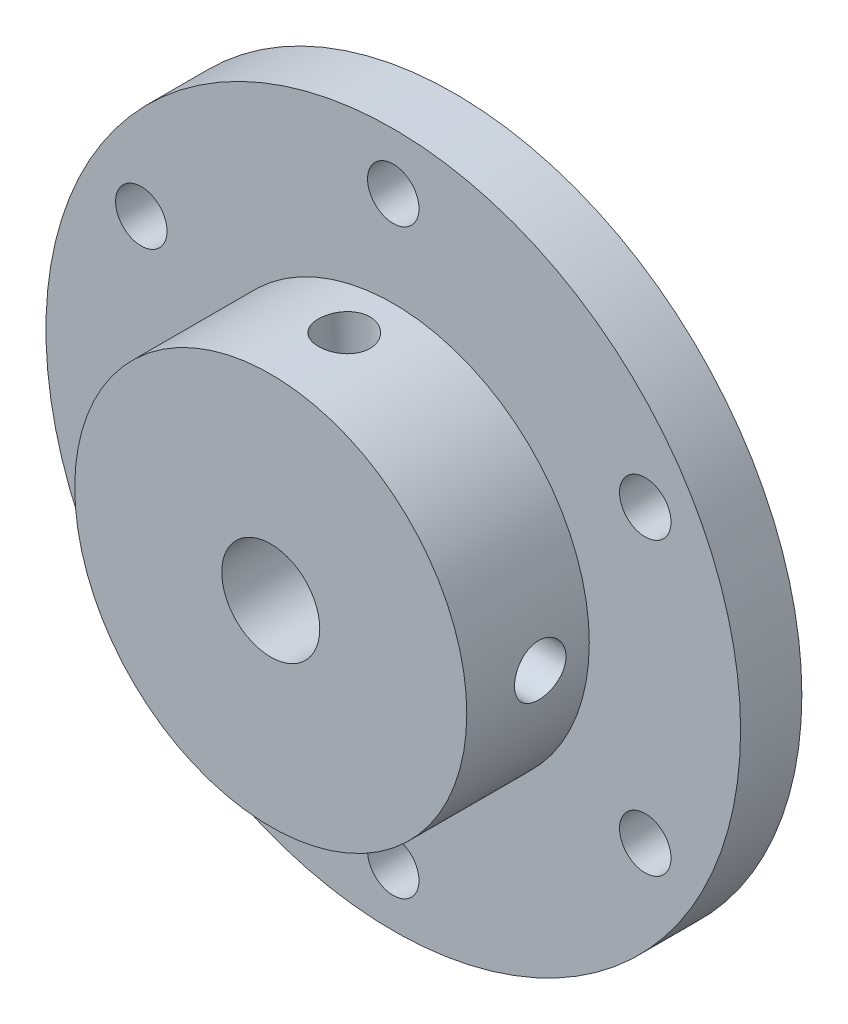
from build123d import *

# Parameters (mm, degrees)
SKETCH_1_R               = 28.35
EXTRUDE_1_DEPTH          = 5
SKETCH_2_R               = 16
EXTRUDE_2_DEPTH          = 10
SKETCH_3_R               = 4
CUT_EXTRUDE_1_DEPTH      = 43.807067174
M5X0_8_1_D               = 4.2
PATTERN_CIRCULAR_1_COUNT = 6
SKETCH_11_W              = 2.1
SKETCH_11_H              = 16.001
PATTERN_CIRCULAR_2_COUNT = 2
PATTERN_CIRCULAR_2_ANGLE = 90
BOSS_EXTRUDE1_DEPTH      = 15


with BuildPart() as part:
    # 草圖1 → 填料-伸長1 (new body)
    with BuildSketch(Plane.XY):
        Circle(SKETCH_1_R)
    extrude(amount=EXTRUDE_1_DEPTH)

    # 草圖2 → 填料-伸長2 (add)
    with BuildSketch(Plane.XY.offset(5)):
        Circle(SKETCH_2_R)
    extrude(amount=EXTRUDE_2_DEPTH)

    # 草圖3 → 除料-伸長1 (cut, through all)
    with BuildSketch(Plane.XY.offset(15)):
        Circle(SKETCH_3_R)
    extrude(amount=-CUT_EXTRUDE_1_DEPTH, mode=Mode.SUBTRACT)

    # M5x0.8 螺紋孔1 (through all)
    with Locations(Plane(origin=(0, 23.75, 5), x_dir=(1, 0, 0), z_dir=(0, 0, 1))):
        with Locations((0, 0)):
            m5x0_8_1 = Hole(M5X0_8_1_D / 2)

    # 環狀複製排列1: M5x0.8 螺紋孔1 ×6 about axis
    pattern_circular_1_axis = Axis((0, 0, 0), (0, 0, 1))
    for i in range(1, PATTERN_CIRCULAR_1_COUNT):
        add(m5x0_8_1.rotate(pattern_circular_1_axis, i * 360 / PATTERN_CIRCULAR_1_COUNT), mode=Mode.SUBTRACT)

    # 草圖11 → M5x0.8 螺紋孔2 (revolve, cut)
    with BuildSketch(Plane(origin=(0, 0, 9), x_dir=(0, 0, 1), z_dir=(0, 1, 0))):
        with Locations((1.05, 8.0005)):
            Rectangle(SKETCH_11_W, SKETCH_11_H)
    m5x0_8_2 = revolve(axis=Axis((-6.35, 0, 9), (1, 0, 0)), mode=Mode.SUBTRACT)

    # 環狀複製排列2: M5x0.8 螺紋孔2 ×2 about axis
    pattern_circular_2_axis = Axis((0, 0, 15), (0, 0, 1))
    for i in range(1, PATTERN_CIRCULAR_2_COUNT):
        add(m5x0_8_2.rotate(pattern_circular_2_axis, i * PATTERN_CIRCULAR_2_ANGLE / (PATTERN_CIRCULAR_2_COUNT - 1)), mode=Mode.SUBTRACT)

    # Sketch1 → Boss-Extrude1 (add)
    with BuildSketch(Plane.XY.offset(15)):
        with BuildLine():
            ThreePointArc((4, 0), (1.414213562, 3.741657387), (-3, 2.645751311))
            Line((-3, 2.645751311), (-3, -2.645751311))
            ThreePointArc((-3, -2.645751311), (1.414213562, -3.741657387), (4, 0))
        make_face()
        with BuildLine():
            Line((-3, -2.645751311), (-3, 2.645751311))
            ThreePointArc((-3, 2.645751311), (-3.999997422, 0.0045417), (-3.006000366, -2.638931943))
            ThreePointArc((-3.006000366, -2.638931943), (-3.003002119, -2.64234333), (-3, -2.645751311))
        make_face()
    extrude(amount=BOSS_EXTRUDE1_DEPTH)


with BuildPart() as boss_extrude1_kept_piece:
    # of the separate pieces the step leaves, the one the design keeps (boss_extrude1_pieces_kept)
    add(part.part.solids().sort_by_distance((28.35, 0, 0))[0])


solid = boss_extrude1_kept_piece.part
